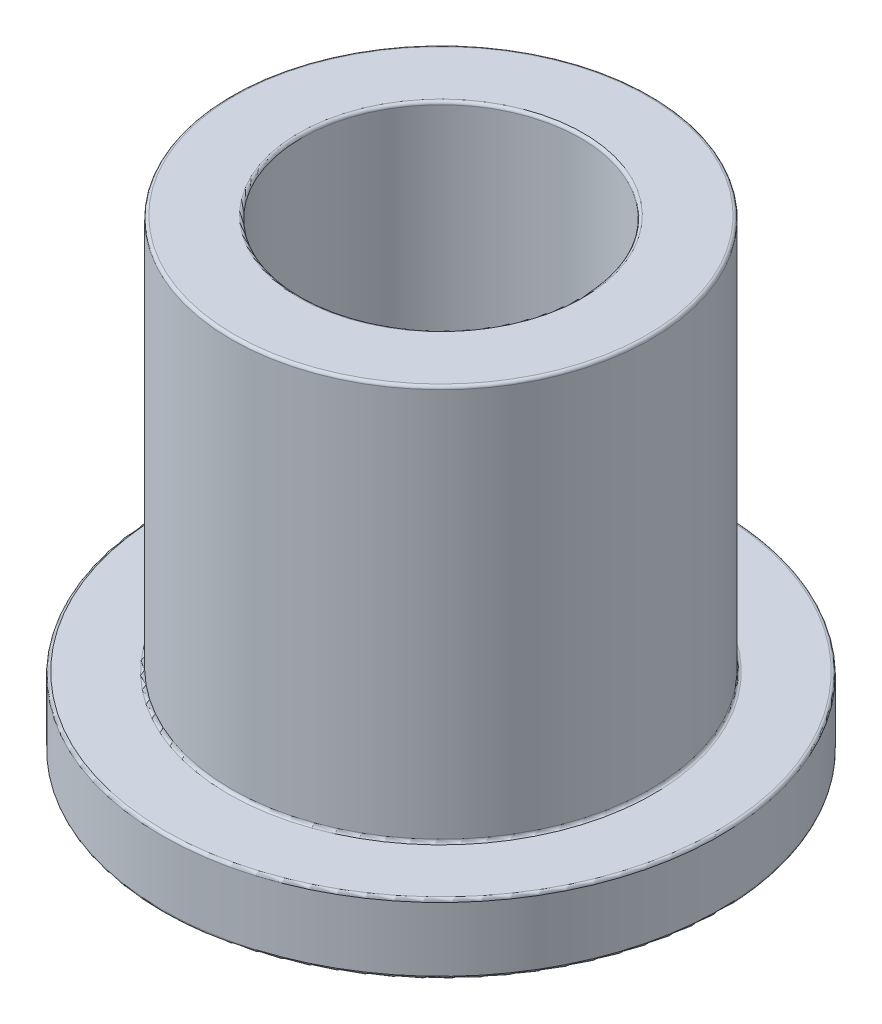
from build123d import *

# Parameters (mm, degrees)
SKETCH3_R           = 9.015
SKETCH3_R_2         = 6.005
BOSS_EXTRUDE1_DEPTH = 20
SKETCH4_R           = 12
SKETCH4_R_2         = 9.015
BOSS_EXTRUDE2_DEPTH = 3
FILLET1_R           = 0.125


with BuildPart() as part:
    # Sketch3 → Boss-Extrude1 (new body)
    with BuildSketch(Plane(origin=(0, 0, 0), x_dir=(1, 0, 0), z_dir=(0, 1, 0))):
        Circle(SKETCH3_R)
        Circle(SKETCH3_R_2, mode=Mode.SUBTRACT)
    extrude(amount=BOSS_EXTRUDE1_DEPTH)

    # Sketch4 → Boss-Extrude2 (add)
    with BuildSketch(Plane(origin=(0, 0, 0), x_dir=(1, 0, 0), z_dir=(0, 1, 0))):
        Circle(SKETCH4_R)
        Circle(SKETCH4_R_2, mode=Mode.SUBTRACT)
    extrude(amount=BOSS_EXTRUDE2_DEPTH)

    # Fillet1
    fillet1_edges = [part.edges().sort_by_distance(p)[0] for p in [
        (-12, 0, 0),
        (-9.015, 3, 0),
        (-9.015, 20, 0),
        (-6.005, 0, 0),
        (-6.005, 20, 0),
        (-12, 3, 0),
    ]]
    fillet(fillet1_edges, radius=FILLET1_R)


solid = part.part
